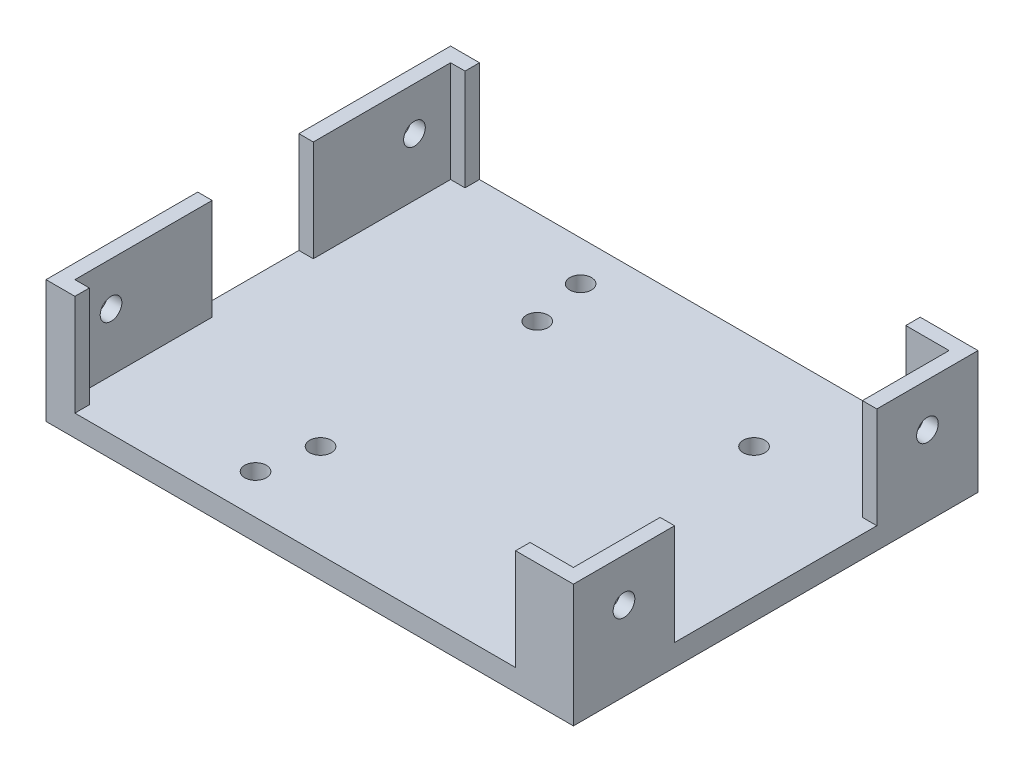
from build123d import *

# Parameters (mm, degrees)
SKETCH1_W               = 73
SKETCH1_H               = 56
BOSS_EXTRUDE1_DEPTH     = 3
SKETCH2_R               = 1.5
CUT_EXTRUDE1_DEPTH      = 4
SKETCH4_W               = 2
SKETCH4_H               = 12
SKETCH4_H_2             = 19
SKETCH4_W_2             = 8
SKETCH4_H_3             = 2
BOSS_EXTRUDE2_DEPTH     = 14
SKETCH5_R               = 1.5
CUT_EXTRUDE2_DEPTH      = 4
SKETCH7_R               = 1.5
CUT_EXTRUDE4_DEPTH      = 1
CUT_EXTRUDE4_DEPTH_BACK = 74


with BuildPart() as part:
    # Sketch1 → Boss-Extrude1 (new body)
    with BuildSketch(Plane(origin=(0, 0, 0), x_dir=(1, 0, 0), z_dir=(0, 1, 0))):
        with Locations((-1.12052506, -6.090692124)):
            Rectangle(SKETCH1_W, SKETCH1_H)
    extrude(amount=BOSS_EXTRUDE1_DEPTH)

    # Sketch2 → Cut-Extrude1 (cut, through all)
    with BuildSketch(Plane(origin=(0, 3, 0), x_dir=(1, 0, 0), z_dir=(0, 1, 0))):
        with Locations((-12.62052506, 8.909307876)):
            Circle(SKETCH2_R)
        with Locations((-12.62052506, -21.090692124)):
            Circle(SKETCH2_R)
        with Locations((17.37947494, -21.090692124)):
            Circle(SKETCH2_R)
        with Locations((17.37947494, 8.909307876)):
            Circle(SKETCH2_R)
    extrude(amount=-CUT_EXTRUDE1_DEPTH, mode=Mode.SUBTRACT)

    # Sketch4 → Boss-Extrude2 (add)
    with BuildSketch(Plane(origin=(0, 3, 0), x_dir=(1, 0, 0), z_dir=(0, 1, 0))):
        Polygon((-33.62052506, 21.909307876), (-37.62052506, 21.909307876), (-37.62052506, 19.909307876), (-35.62052506, 19.909307876), (-33.62052506, 19.909307876), align=None)
        Polygon((35.37947494, 21.909307876), (27.37947494, 21.909307876), (27.37947494, 19.909307876), (33.37947494, 19.909307876), (35.37947494, 19.909307876), align=None)
        with Locations((34.37947494, 13.909307876)):
            Rectangle(SKETCH4_W, SKETCH4_H)
        with Locations((34.37947494, -26.090692124)):
            Rectangle(SKETCH4_W, SKETCH4_H)
        Polygon((-35.62052506, -32.090692124), (-37.62052506, -32.090692124), (-37.62052506, -34.090692124), (-33.62052506, -34.090692124), (-33.62052506, -32.090692124), align=None)
        with Locations((-36.62052506, -22.590692124)):
            Rectangle(SKETCH4_W, SKETCH4_H_2)
        with Locations((-36.62052506, 10.409307876)):
            Rectangle(SKETCH4_W, SKETCH4_H_2)
        with Locations((31.37947494, -33.090692124)):
            Rectangle(SKETCH4_W_2, SKETCH4_H_3)
    extrude(amount=BOSS_EXTRUDE2_DEPTH)

    # Sketch5 → Cut-Extrude2 (cut, through all)
    with BuildSketch(Plane(origin=(0, 3, 0), x_dir=(1, 0, 0), z_dir=(0, 1, 0))):
        with Locations((30.87947494, 16.409307876)):
            Circle(SKETCH5_R)
        with Locations((30.87947494, -28.590692124)):
            Circle(SKETCH5_R)
        with Locations((-14.12052506, 16.409307876)):
            Circle(SKETCH5_R)
        with Locations((-14.12052506, -28.590692124)):
            Circle(SKETCH5_R)
    extrude(amount=-CUT_EXTRUDE2_DEPTH, mode=Mode.SUBTRACT)

    # Sketch7 → Cut-Extrude4 (cut, two sides)
    with BuildSketch(Plane(origin=(35.37947494, 0, 0), x_dir=(0, 0, -1), z_dir=(1, 0, 0))) as cut_extrude4_sk:
        with Locations((-27.090692124, 11)):
            Circle(SKETCH7_R)
        with Locations((14.909307876, 11)):
            Circle(SKETCH7_R)
    extrude(amount=CUT_EXTRUDE4_DEPTH, mode=Mode.SUBTRACT)
    extrude(cut_extrude4_sk.sketch, amount=-CUT_EXTRUDE4_DEPTH_BACK, mode=Mode.SUBTRACT)


solid = part.part
